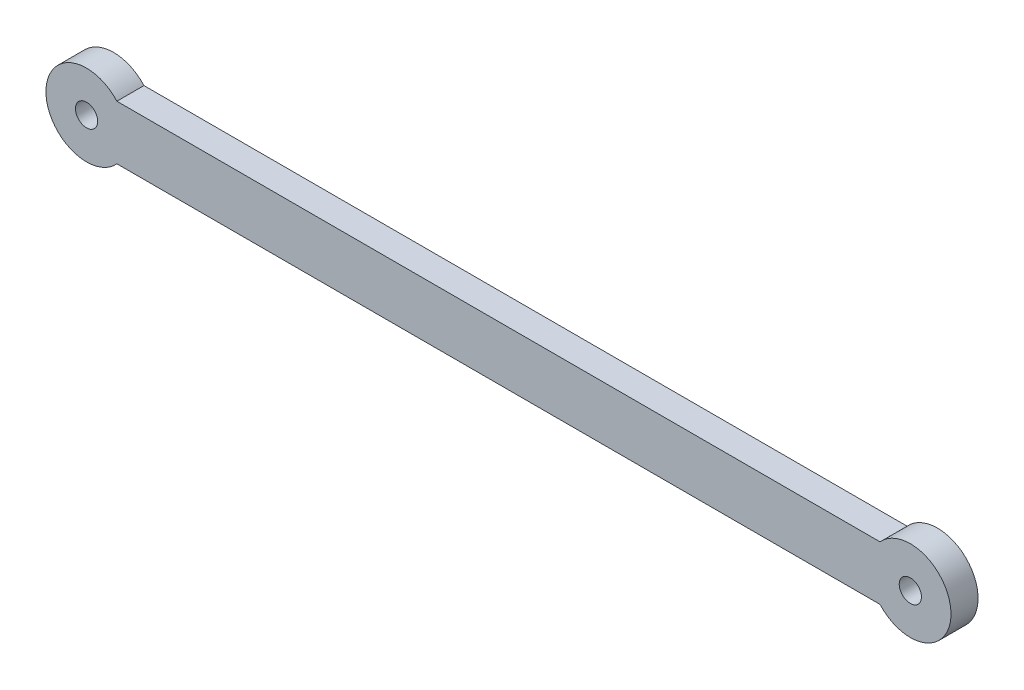
from build123d import *

# Parameters (mm, degrees)
SCHIZZO1_R                   = 2.05
ESTRUSIONE_ESTRUSIONE1_DEPTH = 5


with BuildPart() as part:
    # Schizzo1 → Estrusione-Estrusione1 (new body)
    with BuildSketch(Plane.XY):
        with BuildLine():
            Line((5.590169944, -5), (146.409830056, -5))
            ThreePointArc((146.409830056, -5), (159.5, 0), (146.409830056, 5))
            Line((146.409830056, 5), (5.590169944, 5))
            ThreePointArc((5.590169944, 5), (-7.5, 0), (5.590169944, -5))
        make_face()
        Circle(SCHIZZO1_R, mode=Mode.SUBTRACT)
        with Locations((152, 0)):
            Circle(SCHIZZO1_R, mode=Mode.SUBTRACT)
    extrude(amount=ESTRUSIONE_ESTRUSIONE1_DEPTH)


solid = part.part
